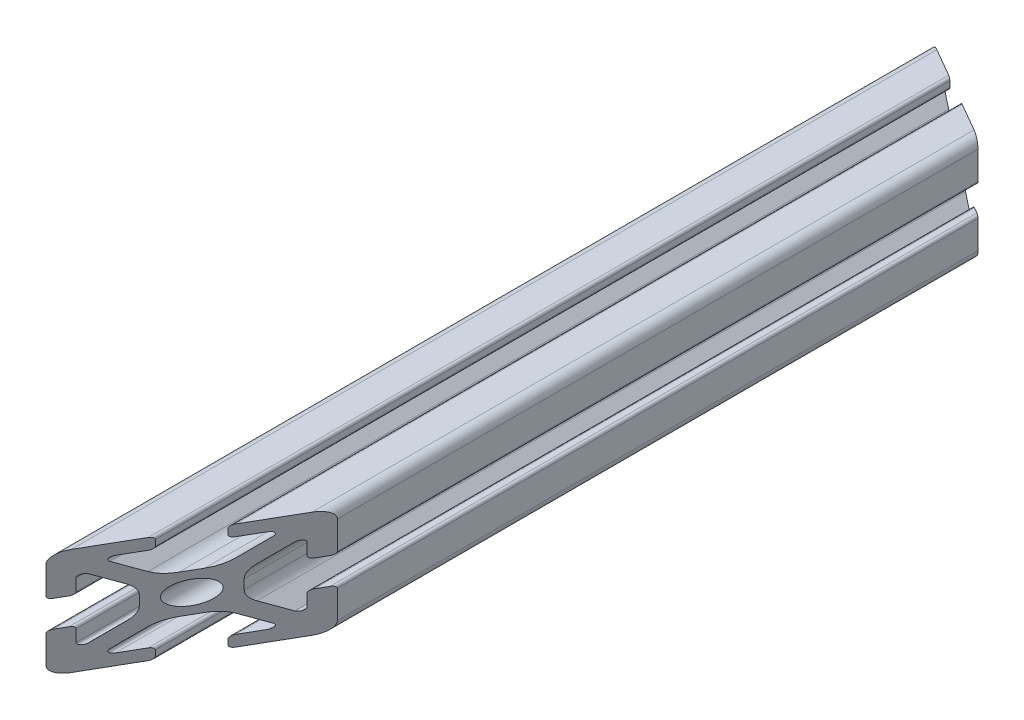
from build123d import *

# Parameters (mm, degrees)
BOSS_EXTRUDE1_DEPTH = 100
SKETCH5_OUTSIDE_W   = 62.398
SKETCH5_OUTSIDE_H   = 242.398
CUT_EXTRUDE1_DEPTH  = 21


with BuildPart() as part:
    # Sketch4 → Boss-Extrude1 (new body, symmetric)
    with BuildSketch(Plane.XY):
        with BuildLine():
            Line((3, -10), (8.25, -10))
            ThreePointArc((8.25, -10), (9.487436867, -9.487436867), (10, -8.25))
            Line((10, -8.25), (10, -3))
            ThreePointArc((10, -3), (9.853553391, -2.646446609), (9.5, -2.5))
            Line((9.5, -2.5), (8.424621202, -2.5))
            ThreePointArc((8.424621202, -2.5), (8.071067812, -2.646446609), (7.924621202, -3))
            Line((7.924621202, -3), (7.924621202, -5.25))
            ThreePointArc((7.924621202, -5.25), (7.615962919, -5.711939766), (7.071067812, -5.603553391))
            Line((7.071067812, -5.603553391), (4.478679656, -3.011165235))
            ThreePointArc((4.478679656, -3.011165235), (3.828361402, -2.037895189), (3.6, -0.889844892))
            Line((3.6, -0.889844892), (3.6, 0))
            Line((3.6, 0), (2.15, 0))
            ThreePointArc((2.15, 0), (1.52027958, -1.52027958), (0, -2.15))
            Line((0, -2.15), (0, -3.6))
            Line((0, -3.6), (0.889844892, -3.6))
            ThreePointArc((0.889844892, -3.6), (2.037895189, -3.828361402), (3.011165235, -4.478679656))
            Line((3.011165235, -4.478679656), (5.603553391, -7.071067812))
            ThreePointArc((5.603553391, -7.071067812), (5.711939766, -7.615962919), (5.25, -7.924621202))
            Line((5.25, -7.924621202), (3, -7.924621202))
            ThreePointArc((3, -7.924621202), (2.646446609, -8.071067812), (2.5, -8.424621202))
            Line((2.5, -8.424621202), (2.5, -9.5))
            ThreePointArc((2.5, -9.5), (2.646446609, -9.853553391), (3, -10))
        make_face()
    extrude(amount=BOSS_EXTRUDE1_DEPTH, both=True)

    # Mirror1: part across plane


with BuildPart() as part_1:
    add(part.part)
    add(part.part.mirror(Plane(origin=(0, 0, 0), x_dir=(0, 0, 1), z_dir=(1, 0, 0))))

    # Mirror2: part across plane


with BuildPart() as part_2:
    add(part_1.part)
    add(part_1.part.mirror(Plane.ZX))

    # Sketch5 outside → Cut-Extrude1 (cut, through all)
    with BuildSketch(Plane(origin=(0, 10, 0), x_dir=(1, 0, 0), z_dir=(0, 1, 0))):
        Rectangle(SKETCH5_OUTSIDE_W, SKETCH5_OUTSIDE_H)
        Polygon((-10, -100), (62, 24.707658145), (-11.612159322, 67.207658145), align=None, mode=Mode.SUBTRACT)
    extrude(amount=-CUT_EXTRUDE1_DEPTH, mode=Mode.SUBTRACT)


solid = part_2.part
